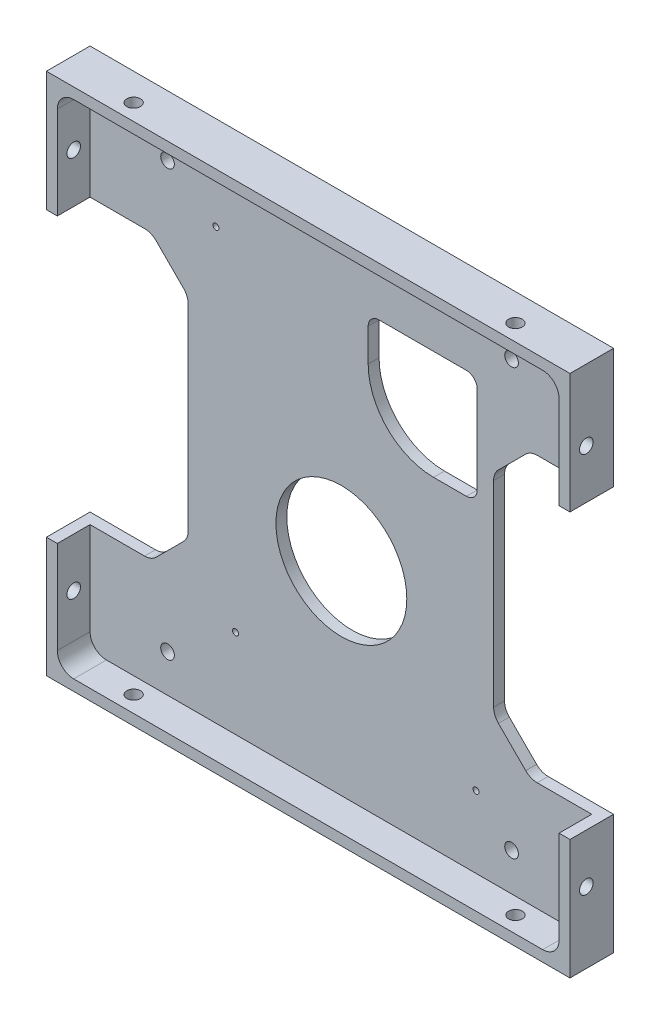
from build123d import *

# Parameters (mm, degrees)
SKETCH1_W                      = 96
SKETCH1_H                      = 96
BOSS_EXTRUDE1_DEPTH            = 8
SKETCH2_W                      = 92
SKETCH2_H                      = 92
COMPONENT_PLATFORM_DEPTH       = 6
CABLE_SLOTS_DEPTH              = 6
INNER_CORNER_FILLETS_R         = 3
M3X0_5_TAPPED_HOLE1_AT_2_COUNT = 2
M3X0_5_TAPPED_HOLE1_AT_2_PITCH = 70
M3X0_5_TAPPED_HOLE2_AT_2_COUNT = 2
M3X0_5_TAPPED_HOLE2_AT_2_PITCH = 70
M1_4X0_3_TAPPED_HOLE1_D        = 1.1
M1_4X0_3_TAPPED_HOLE1_DEPTH    = 3.7
M1_4X0_3_TAPPED_HOLE1_TIP      = 0.33047334
SKETCH29_R                     = 12
HDD_EXTRUSION_CUTOUT_DEPTH     = 10
HDD_EXTRUSION_CUTOUT_2_DEPTH   = 10
M3X0_5_TAPPED_HOLE3_D          = 2.5
M3X0_5_TAPPED_HOLE3_DEPTH      = 10
M3X0_5_TAPPED_HOLE3_TIP        = 0.751075774


with BuildPart() as part:
    # Sketch1 → Boss-Extrude1 (new body)
    with BuildSketch(Plane.XY):
        Rectangle(SKETCH1_W, SKETCH1_H)
    extrude(amount=BOSS_EXTRUDE1_DEPTH)

    # Sketch2 → Component Platform (cut)
    with BuildSketch(Plane.XY.offset(8)):
        Rectangle(SKETCH2_W, SKETCH2_H)
    extrude(amount=-COMPONENT_PLATFORM_DEPTH, mode=Mode.SUBTRACT)

    # Sketch3 → Cable Slots (cut, symmetric)
    with BuildSketch(Plane.XY.offset(2)):
        with BuildLine():
            Line((-33.878679656, -25.121320344), (-28.878679656, -20.121320344))
            ThreePointArc((-28.878679656, -20.121320344), (-28.228361402, -19.148050297), (-28, -18))
            Line((-28, -18), (-28, 18))
            ThreePointArc((-28, 18), (-28.228361402, 19.148050297), (-28.878679656, 20.121320344))
            Line((-28.878679656, 20.121320344), (-33.878679656, 25.121320344))
            ThreePointArc((-33.878679656, 25.121320344), (-34.851949703, 25.771638598), (-36, 26))
            Line((-36, 26), (-48, 26))
            Line((-48, 26), (-48, -26))
            Line((-48, -26), (-36, -26))
            ThreePointArc((-36, -26), (-34.851949703, -25.771638598), (-33.878679656, -25.121320344))
        make_face()
        with BuildLine():
            Line((48, -26), (48, 26))
            Line((48, 26), (36, 26))
            ThreePointArc((36, 26), (34.851949703, 25.771638598), (33.878679656, 25.121320344))
            Line((33.878679656, 25.121320344), (28.878679656, 20.121320344))
            ThreePointArc((28.878679656, 20.121320344), (28.228361402, 19.148050297), (28, 18))
            Line((28, 18), (28, -18))
            ThreePointArc((28, -18), (28.228361402, -19.148050297), (28.878679656, -20.121320344))
            Line((28.878679656, -20.121320344), (33.878679656, -25.121320344))
            ThreePointArc((33.878679656, -25.121320344), (34.851949703, -25.771638598), (36, -26))
            Line((36, -26), (48, -26))
        make_face()
    extrude(amount=CABLE_SLOTS_DEPTH, both=True, mode=Mode.SUBTRACT)

    # Inner Corner Fillets
    inner_corner_fillets_edges = [part.edges().sort_by_distance(p)[0] for p in [
        (-46, -46, 5),
        (-46, 46, 5),
        (46, 46, 5),
        (46, -46, 5),
    ]]
    fillet(inner_corner_fillets_edges, radius=INNER_CORNER_FILLETS_R)

    # Sketch14 → M3x0.5 Tapped Hole1 (revolve, cut)
    with BuildSketch(Plane(origin=(48, -35, 5), x_dir=(0, 0, -1), z_dir=(0, 1, 0))):
        Polygon((0, 0), (0, 10.751075774), (1.25, 10), (1.25, 0), align=None)
    m3x0_5_tapped_hole1 = revolve(axis=Axis((54.35, -35, 5), (-1, 0, 0)), mode=Mode.SUBTRACT)

    # M3x0.5 Tapped Hole1 at 2: M3x0.5 Tapped Hole1 ×2
    with Locations(*[(0, i * M3X0_5_TAPPED_HOLE1_AT_2_PITCH, 0) for i in range(1, M3X0_5_TAPPED_HOLE1_AT_2_COUNT)]):
        add(m3x0_5_tapped_hole1, mode=Mode.SUBTRACT)

    # Sketch16 → M3x0.5 Tapped Hole2 (revolve, cut)
    with BuildSketch(Plane(origin=(35, 48, 5), x_dir=(0, 0, 1), z_dir=(1, 0, 0))):
        Polygon((0, 0), (0, 10.751075774), (1.25, 10), (1.25, 0), align=None)
    m3x0_5_tapped_hole2 = revolve(axis=Axis((35, 54.35, 5), (0, -1, 0)), mode=Mode.SUBTRACT)

    # M3x0.5 Tapped Hole2 at 2: M3x0.5 Tapped Hole2 ×2
    with Locations(*[(-i * M3X0_5_TAPPED_HOLE2_AT_2_PITCH, 0, 0) for i in range(1, M3X0_5_TAPPED_HOLE2_AT_2_COUNT)]):
        add(m3x0_5_tapped_hole2, mode=Mode.SUBTRACT)

    # Mirror1: M3x0.5 Tapped Hole1 across plane
    add(m3x0_5_tapped_hole1.mirror(Plane(origin=(0, 0, 0), x_dir=(0, 0, 1), z_dir=(1, 0, 0))), mode=Mode.SUBTRACT)

    # Mirror1 copy 1 sketch → Mirror1 copy 1 (revolve, cut)
    with BuildSketch(Plane(origin=(-48, 35, 5), x_dir=(0, 0, -1), z_dir=(0, 1, 0))):
        Polygon((0, 0), (0, -10.751075774), (1.25, -10), (1.25, 0), align=None)
    revolve(axis=Axis((-54.35, 35, 5), (-1, 0, 0)), mode=Mode.SUBTRACT)

    # Mirror2: M3x0.5 Tapped Hole2 across plane
    add(m3x0_5_tapped_hole2.mirror(Plane(origin=(0, 0, 0), x_dir=(0, 0, 1), z_dir=(0, -1, 0))), mode=Mode.SUBTRACT)

    # Mirror2 copy 1 sketch → Mirror2 copy 1 (revolve, cut)
    with BuildSketch(Plane(origin=(-35, -48, 5), x_dir=(0, 0, 1), z_dir=(1, 0, 0))):
        Polygon((0, 0), (0, -10.751075774), (1.25, -10), (1.25, 0), align=None)
    revolve(axis=Axis((-35, -54.35, 5), (0, -1, 0)), mode=Mode.SUBTRACT)

    # M1.4x0.3 Tapped Hole1
    with Locations(Plane.XY.offset(2)):
        with Locations((-19.31998517, -29.75), (24.78001483, -32.85), (-22.91998517, 32.85)):
            Hole(M1_4X0_3_TAPPED_HOLE1_D / 2, depth=M1_4X0_3_TAPPED_HOLE1_DEPTH)
            with Locations((0, 0, -(M1_4X0_3_TAPPED_HOLE1_DEPTH + M1_4X0_3_TAPPED_HOLE1_TIP / 2))):  # 118° drill point
                Cone(0, M1_4X0_3_TAPPED_HOLE1_D / 2, M1_4X0_3_TAPPED_HOLE1_TIP, mode=Mode.SUBTRACT)

    # Sketch29 → HDD Extrusion Cutout (cut)
    with BuildSketch(Plane(origin=(0, 0, 0), x_dir=(-1, 0, 0), z_dir=(0, 0, -1))):
        with Locations((-0.08192631, -8.74785827)):
            Circle(SKETCH29_R)
    extrude(amount=-HDD_EXTRUSION_CUTOUT_DEPTH, mode=Mode.SUBTRACT)

    # Sketch9 → HDD Extrusion Cutout 2 (cut)
    with BuildSketch(Plane.XY.offset(2)):
        with BuildLine():
            Line((25, 31), (25, 15))
            ThreePointArc((25, 15), (24.414213562, 13.585786438), (23, 13))
            Line((23, 13), (17, 13))
            ThreePointArc((17, 13), (8.514718626, 16.514718626), (5, 25))
            Line((5, 25), (5, 31))
            ThreePointArc((5, 31), (5.585786438, 32.414213562), (7, 33))
            Line((7, 33), (23, 33))
            ThreePointArc((23, 33), (24.414213562, 32.414213562), (25, 31))
        make_face()
    extrude(amount=-HDD_EXTRUSION_CUTOUT_2_DEPTH, mode=Mode.SUBTRACT)

    # M3x0.5 Tapped Hole3
    with Locations(Plane.XY.offset(2)):
        with Locations((-31.790998517, -39.06), (31.29001483, -39.06), (31.29001483, 38.94), (-31.790998517, 38.94)):
            Hole(M3X0_5_TAPPED_HOLE3_D / 2, depth=M3X0_5_TAPPED_HOLE3_DEPTH)
            with Locations((0, 0, -(M3X0_5_TAPPED_HOLE3_DEPTH + M3X0_5_TAPPED_HOLE3_TIP / 2))):  # 118° drill point
                Cone(0, M3X0_5_TAPPED_HOLE3_D / 2, M3X0_5_TAPPED_HOLE3_TIP, mode=Mode.SUBTRACT)


solid = part.part
